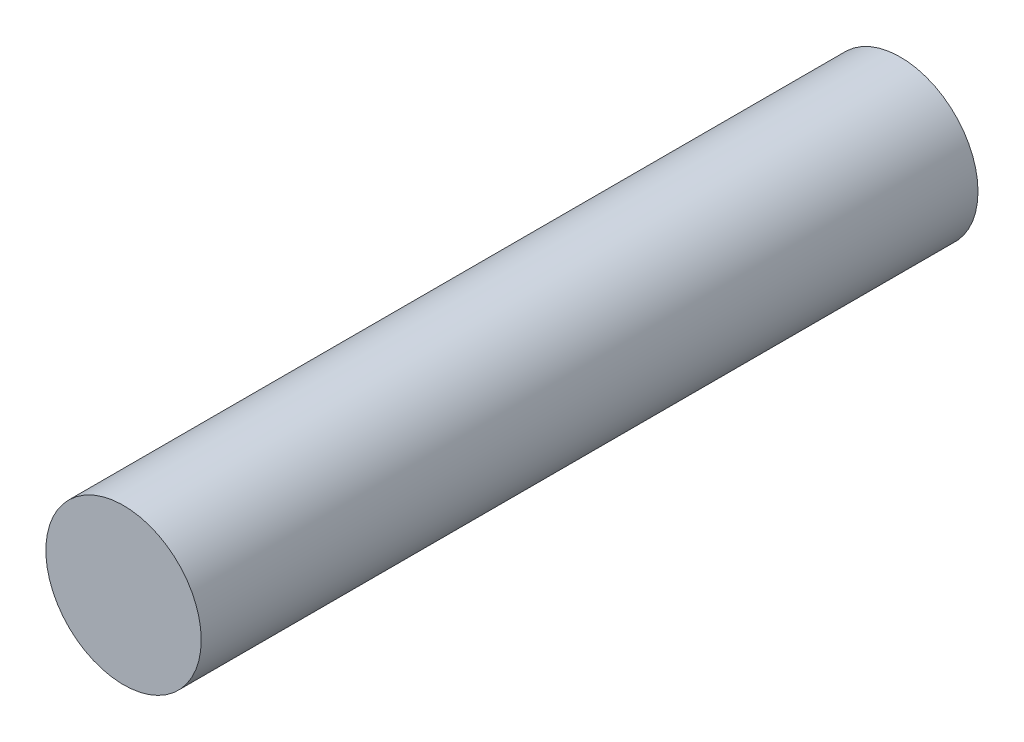
from build123d import *

# Parameters (mm, degrees)
SKETCH1_R           = 1.5
BOSS_EXTRUDE1_DEPTH = 15


with BuildPart() as part:
    # Sketch1 → Boss-Extrude1 (new body)
    with BuildSketch(Plane.XY):
        Circle(SKETCH1_R)
    extrude(amount=BOSS_EXTRUDE1_DEPTH)


solid = part.part
